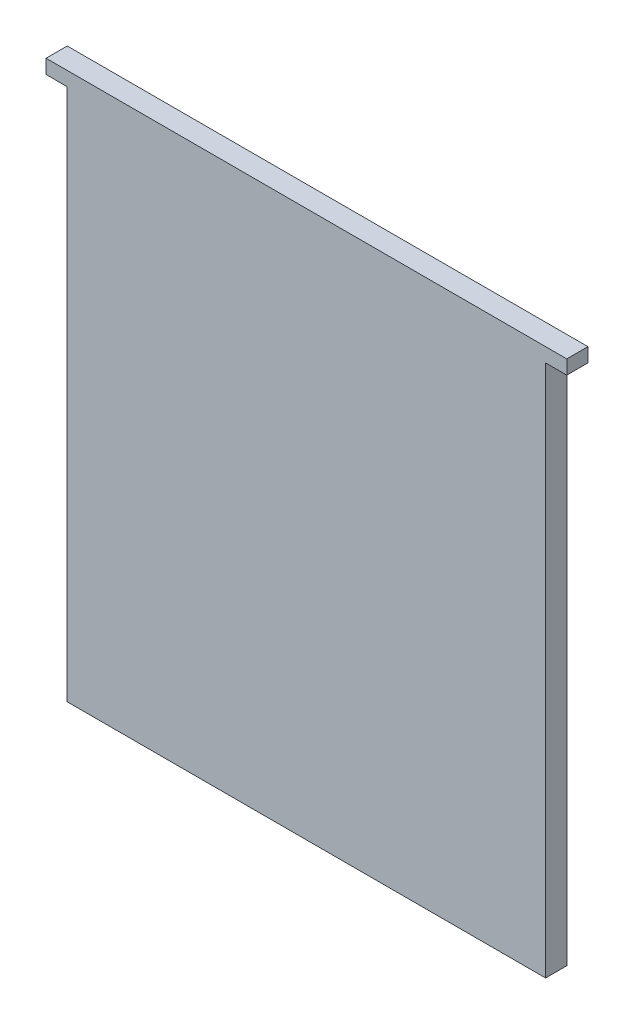
from build123d import *

# Parameters (mm, degrees)
ESBO_O1_W                = 67.8
ESBO_O1_H                = 77.5
RESSALTO_EXTRUS_O1_DEPTH = 3
ESBO_O2_W                = 3
ESBO_O2_H                = 2
RESSALTO_EXTRUS_O2_DEPTH = 3


with BuildPart() as part:
    # Esboço1 → Ressalto-extrusão1 (new body)
    with BuildSketch(Plane.XY):
        Rectangle(ESBO_O1_W, ESBO_O1_H)
    extrude(amount=RESSALTO_EXTRUS_O1_DEPTH)

    # Esboço2 → Ressalto-extrusão2 (add)
    with BuildSketch(Plane.XY.offset(3)):
        with Locations((35.4, 37.75)):
            Rectangle(ESBO_O2_W, ESBO_O2_H)
        with Locations((-35.4, 37.75)):
            Rectangle(ESBO_O2_W, ESBO_O2_H)
    extrude(amount=-RESSALTO_EXTRUS_O2_DEPTH)


solid = part.part
